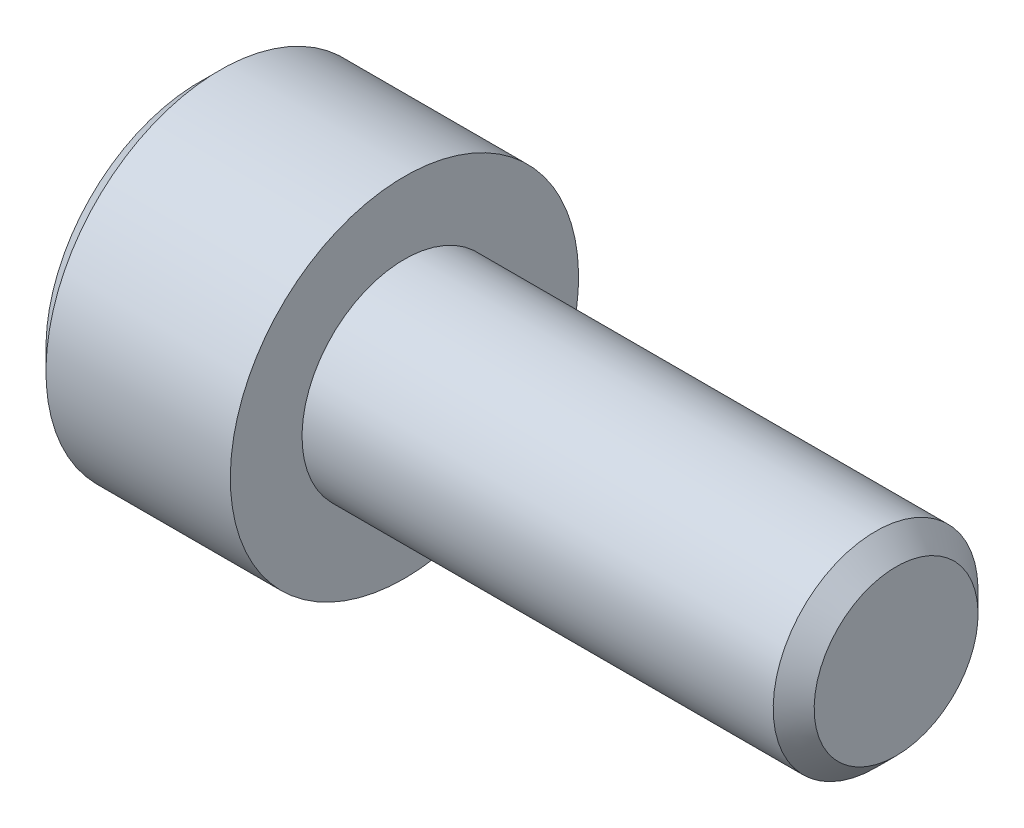
from build123d import *

# Parameters (mm, degrees)
CHAMFER1_SIZE      = 0.5
CUT_EXTRUDE1_DEPTH = 2.5


with BuildPart() as part:
    # Sketch1 → Revolve1 (revolve)
    with BuildSketch(Plane.XY):
        Polygon((-5, 0), (-5, 3.75), (-4.5, 4.25), (0, 4.25), (0, 2.5), (12, 2.5), (12, 0), align=None)
    revolve(axis=Axis((12, 0, 0), (-1, 0, 0)))

    # Chamfer1
    chamfer1_edges = [part.edges().sort_by_distance(p)[0] for p in [
        (12, -2.5, 0),
    ]]
    chamfer(chamfer1_edges, length=CHAMFER1_SIZE)

    # Sketch2 → Cut-Revolve1 (revolve, cut)
    with BuildSketch(Plane.XY):
        Polygon((-5, 0), (-5, 2), (-2.5, 2), (-1.964101615, 0), align=None)
    revolve(axis=Axis((-1.964101615, 0, 0), (-1, 0, 0)), mode=Mode.SUBTRACT)

    # Sketch3 → Cut-Extrude1 (cut)
    with BuildSketch(Plane(origin=(-5, 0, 0), x_dir=(0, 0, -1), z_dir=(1, 0, 0))):
        Polygon((-2, 1.154700538), (-2, -1.154700538), (0, -2.309401077), (2, -1.154700538), (2, 1.154700538), (0, 2.309401077), align=None)
    extrude(amount=CUT_EXTRUDE1_DEPTH, mode=Mode.SUBTRACT)


solid = part.part
